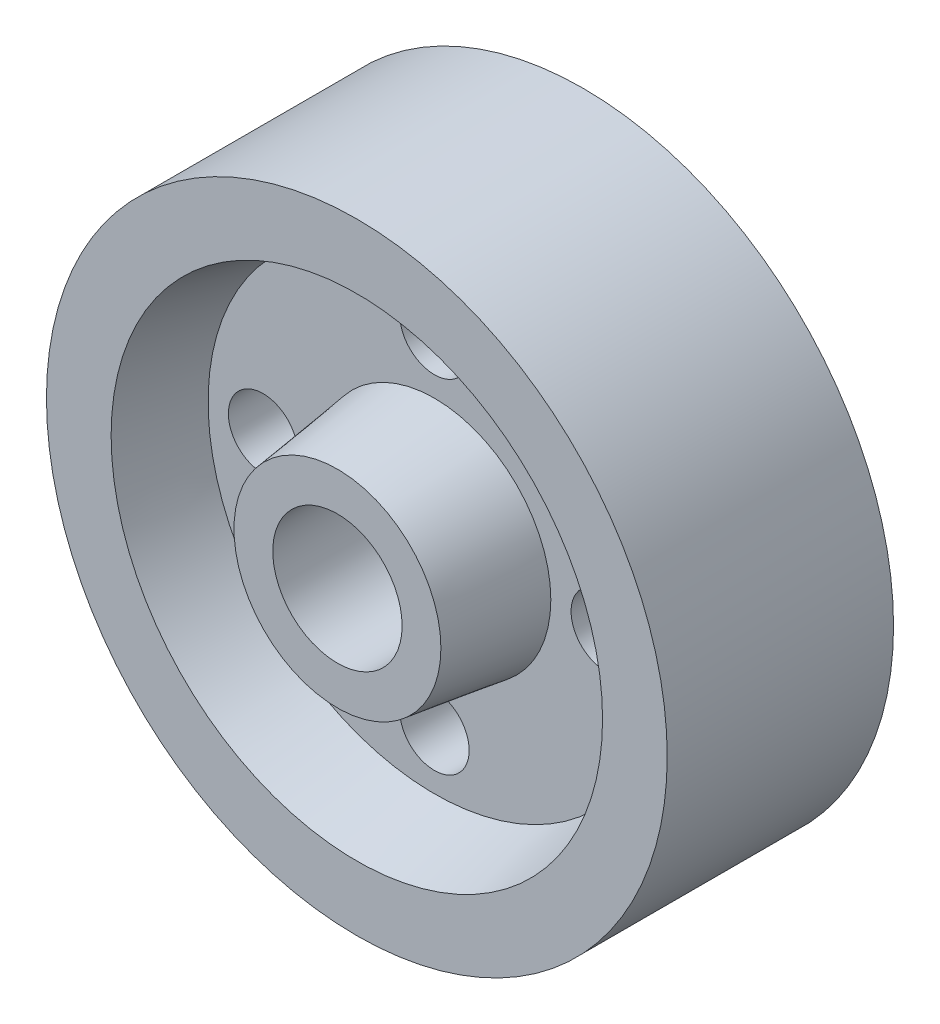
from build123d import *

# Parameters (mm, degrees)
CUT_EXTRUDE1_REACH = 43
SKETCH2_R          = 10
CUT_EXTRUDE2_REACH = 28
SKETCH3_R          = 5.368889336
SKETCH3_4_R        = 5.368889336
CUT_EXTRUDE3_DEPTH = 11


with BuildPart() as part:
    # Sketch1 → Revolve1 (revolve)
    with BuildSketch(Plane(origin=(0, 0, 0), x_dir=(0, 0, -1), z_dir=(1, 0, 0))):
        Polygon((0, 0), (41, 0), (41, 16), (26, 18), (26, 35), (38, 38), (38, 48), (3, 48), (3, 38), (15, 35), (15, 18), (0, 16), align=None)
    revolve(axis=Axis((0, 0, 0), (0, 0, -1)))

    # Sketch2 → Cut-Extrude1 (cut, up to next)
    with BuildSketch(Plane.XY, mode=Mode.PRIVATE) as cut_extrude1_sk1:
        Circle(SKETCH2_R)
    cut_extrude1_tool1 = extrude(cut_extrude1_sk1.sketch, amount=-CUT_EXTRUDE1_REACH, mode=Mode.PRIVATE) & part.part
    add(cut_extrude1_tool1.solids().sort_by_distance((0, 0, 0))[0], mode=Mode.SUBTRACT)

    # Sketch3 → Cut-Extrude2 (cut, up to next)
    with BuildSketch(Plane.XY.offset(-15), mode=Mode.PRIVATE) as cut_extrude2_sk1:
        with Locations((0, 26.5)):
            Circle(SKETCH3_R)
    cut_extrude2_tool1 = extrude(cut_extrude2_sk1.sketch, amount=-CUT_EXTRUDE2_REACH, mode=Mode.PRIVATE) & part.part
    add(cut_extrude2_tool1.solids().sort_by_distance((0, 26.5, -15))[0], mode=Mode.SUBTRACT)

    # Sketch3_4 → Cut-Extrude3 (cut)
    with BuildSketch(Plane.XY.offset(-15)):
        with Locations((0, 26.5)):
            Circle(SKETCH3_4_R)
        with Locations((26.5, 0)):
            Circle(SKETCH3_4_R)
        with Locations((0, -26.5)):
            Circle(SKETCH3_4_R)
        with Locations((-26.5, 0)):
            Circle(SKETCH3_4_R)
    extrude(amount=-CUT_EXTRUDE3_DEPTH, mode=Mode.SUBTRACT)


solid = part.part
